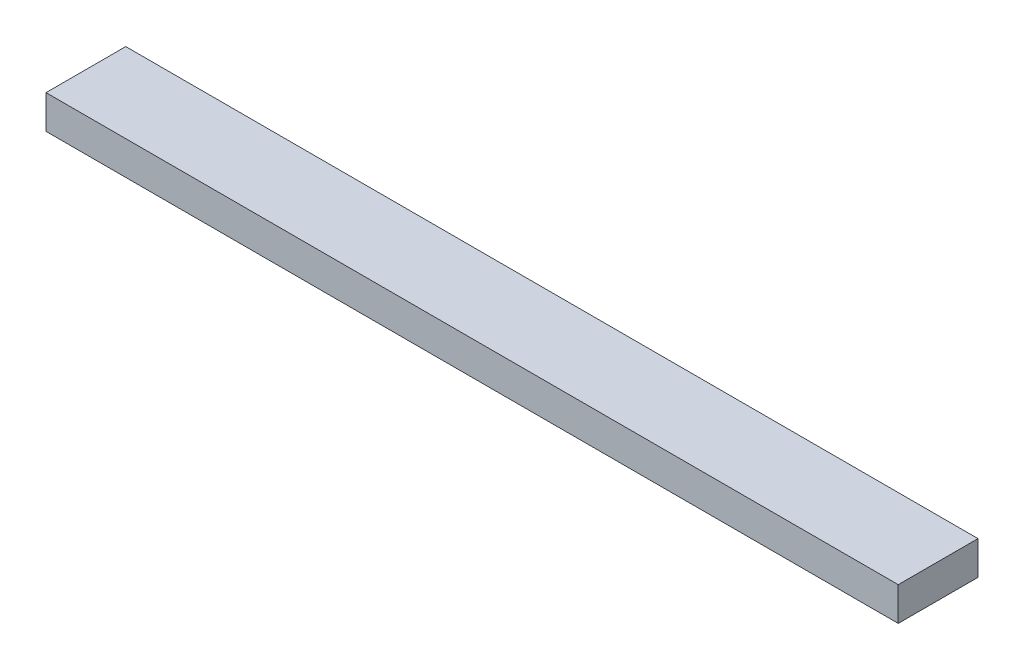
from build123d import *

# Parameters (mm, degrees)
SKETCH1_W           = 101.5
SKETCH1_H           = 9.5
BOSS_EXTRUDE1_DEPTH = 4


with BuildPart() as part:
    # Sketch1 → Boss-Extrude1 (new body)
    with BuildSketch(Plane(origin=(0, 0, 0), x_dir=(1, 0, 0), z_dir=(0, 1, 0))):
        Rectangle(SKETCH1_W, SKETCH1_H)
    extrude(amount=BOSS_EXTRUDE1_DEPTH)


solid = part.part
